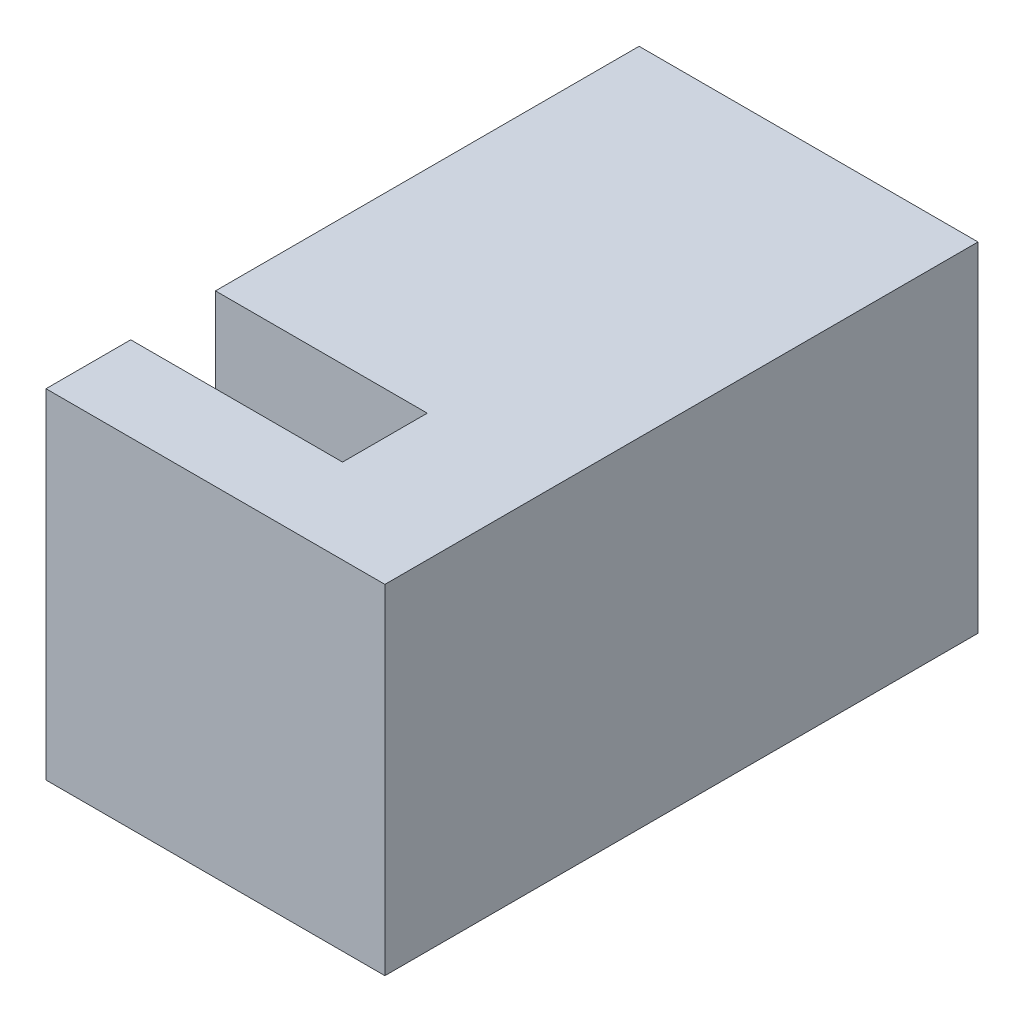
from build123d import *

# Parameters (mm, degrees)
SZKIC1_W                    = 8
SZKIC1_H                    = 8
DODANIE_WYCI_GNI_CIE1_DEPTH = 14
SZKIC2_W                    = 5
SZKIC2_H                    = 2
WYTNIJ_WYCI_GNI_CIE1_DEPTH  = 5
SZKIC3_R                    = 1.375
WYTNIJ_WYCI_GNI_CIE2_DEPTH  = 9


with BuildPart() as part:
    # Szkic1 → Dodanie-wyciągnięcie1 (new body)
    with BuildSketch(Plane.XY):
        with Locations((4, 4)):
            Rectangle(SZKIC1_W, SZKIC1_H)
    extrude(amount=DODANIE_WYCI_GNI_CIE1_DEPTH)

    # Szkic2 → Wytnij-wyciągnięcie1 (cut)
    with BuildSketch(Plane(origin=(0, 8, 0), x_dir=(1, 0, 0), z_dir=(0, 1, 0))):
        with Locations((2.5, -11)):
            Rectangle(SZKIC2_W, SZKIC2_H)
    extrude(amount=-WYTNIJ_WYCI_GNI_CIE1_DEPTH, mode=Mode.SUBTRACT)

    # Szkic3 → Wytnij-wyciągnięcie2 (cut)
    with BuildSketch(Plane(origin=(0, 0, 0), x_dir=(-1, 0, 0), z_dir=(0, 0, -1))):
        with Locations((-4, 4)):
            Circle(SZKIC3_R)
    extrude(amount=-WYTNIJ_WYCI_GNI_CIE2_DEPTH, mode=Mode.SUBTRACT)


solid = part.part
